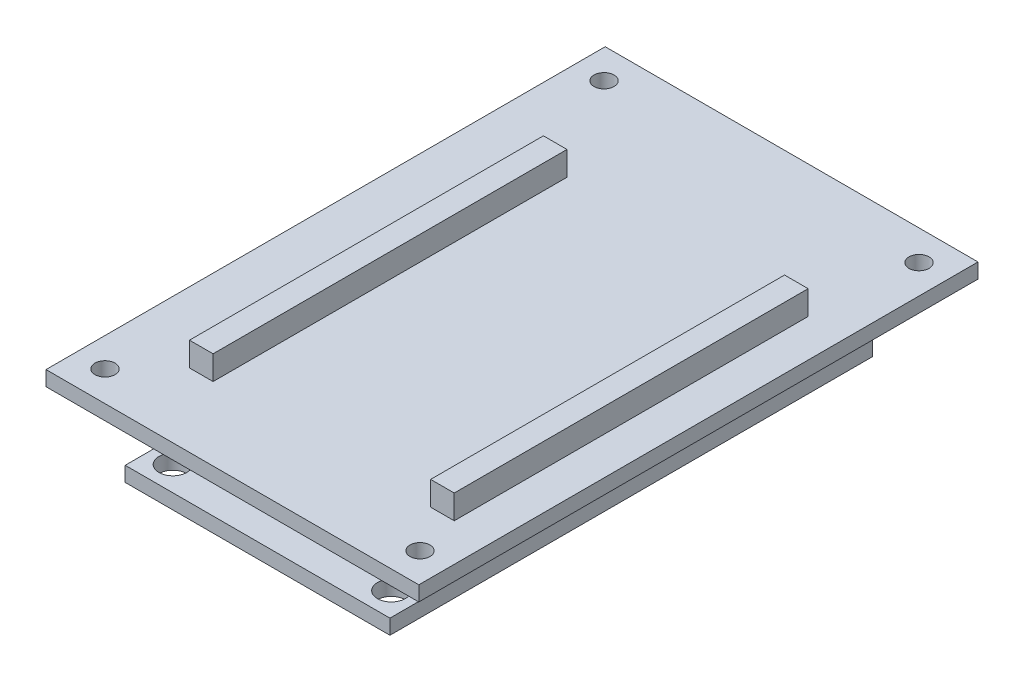
from build123d import *

# Parameters (mm, degrees)
SKETCH1_W           = 28.4988
SKETCH1_H           = 51.943
SKETCH1_R           = 1.4986
BOSS_EXTRUDE1_DEPTH = 1.6002
SKETCH2_W           = 2.54
SKETCH2_H           = 38.1
BOSS_EXTRUDE2_DEPTH = 8.2042
SKETCH3_W           = 15.748
SKETCH3_H           = 17.78
BOSS_EXTRUDE3_DEPTH = 3.2258
SKETCH4_W           = 40.132
SKETCH4_H           = 60.198
SKETCH4_R           = 1.0795
BOSS_EXTRUDE4_DEPTH = 1.6002


with BuildPart() as part:
    # Sketch1 → Boss-Extrude1 (new body)
    with BuildSketch(Plane(origin=(0, 0, 0), x_dir=(1, 0, 0), z_dir=(0, 1, 0))):
        Rectangle(SKETCH1_W, SKETCH1_H)
        with Locations((-11.7602, 23.3299)):
            Circle(SKETCH1_R, mode=Mode.SUBTRACT)
        with Locations((11.7602, -23.3299)):
            Circle(SKETCH1_R, mode=Mode.SUBTRACT)
        with Locations((-11.7602, -23.3299)):
            Circle(SKETCH1_R, mode=Mode.SUBTRACT)
        with Locations((11.7602, 23.3299)):
            Circle(SKETCH1_R, mode=Mode.SUBTRACT)
    extrude(amount=BOSS_EXTRUDE1_DEPTH)

    # Sketch2 → Boss-Extrude2 (add)
    with BuildSketch(Plane(origin=(0, 1.6002, 0), x_dir=(1, 0, 0), z_dir=(0, 1, 0))):
        with Locations((-12.9794, 0)):
            Rectangle(SKETCH2_W, SKETCH2_H)
        with Locations((12.9794, 0)):
            Rectangle(SKETCH2_W, SKETCH2_H)
    extrude(amount=BOSS_EXTRUDE2_DEPTH)

    # Sketch3 → Boss-Extrude3 (add)
    with BuildSketch(Plane.XZ):
        with Locations((0, 9.4615)):
            Rectangle(SKETCH3_W, SKETCH3_H)
    extrude(amount=BOSS_EXTRUDE3_DEPTH)

    # Sketch4 → Boss-Extrude4 (add)
    with BuildSketch(Plane(origin=(0, 5.6134, 0), x_dir=(1, 0, 0), z_dir=(0, 1, 0))):
        with Locations((-1.756423699, 3.175)):
            Rectangle(SKETCH4_W, SKETCH4_H)
        with Locations((-18.710923699, 30.0355)):
            Circle(SKETCH4_R, mode=Mode.SUBTRACT)
        with Locations((15.198076301, 30.0355)):
            Circle(SKETCH4_R, mode=Mode.SUBTRACT)
        with Locations((15.198076301, -23.6855)):
            Circle(SKETCH4_R, mode=Mode.SUBTRACT)
        with Locations((-18.710923699, -23.6855)):
            Circle(SKETCH4_R, mode=Mode.SUBTRACT)
    extrude(amount=BOSS_EXTRUDE4_DEPTH)


solid = part.part
